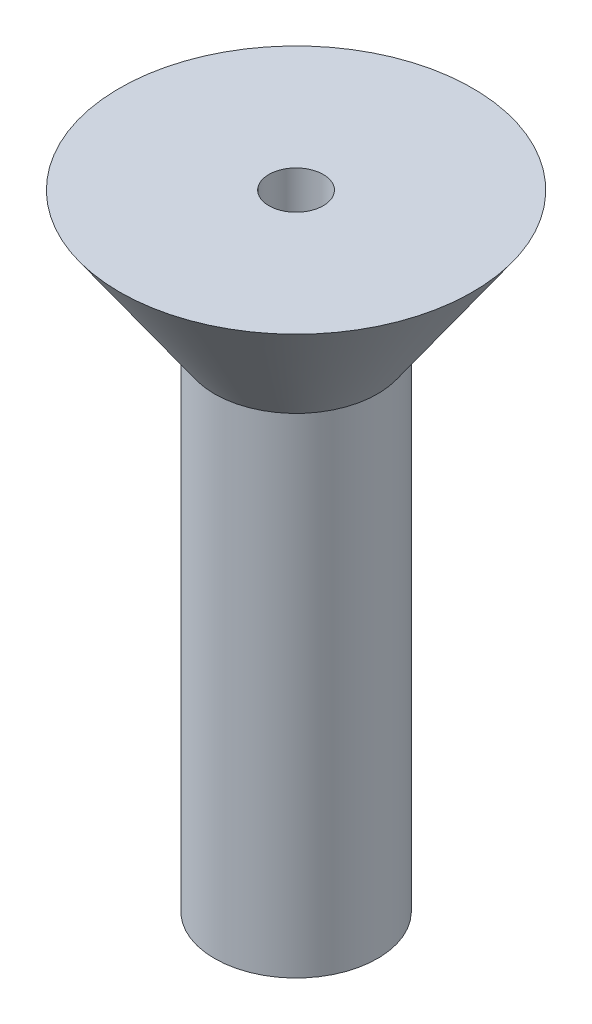
from build123d import *

# Parameters (mm, degrees)
SKETCH1_W = 3
SKETCH1_H = 18


with BuildPart() as part:
    # Sketch1 → Revolve3 (revolve)
    with BuildSketch(Plane.XY):
        Polygon((0, -1.732050808), (0, 0), (-3, 0), align=None)
        with Locations((-1.5, 9)):
            Rectangle(SKETCH1_W, SKETCH1_H)
        Polygon((-3, 18), (0, 18), (0, 21), (-1, 21), (-1, 23), (-6.5, 23), align=None)
    revolve(axis=Axis((0, 91.921344285, 0), (0, -1, 0)))


solid = part.part
